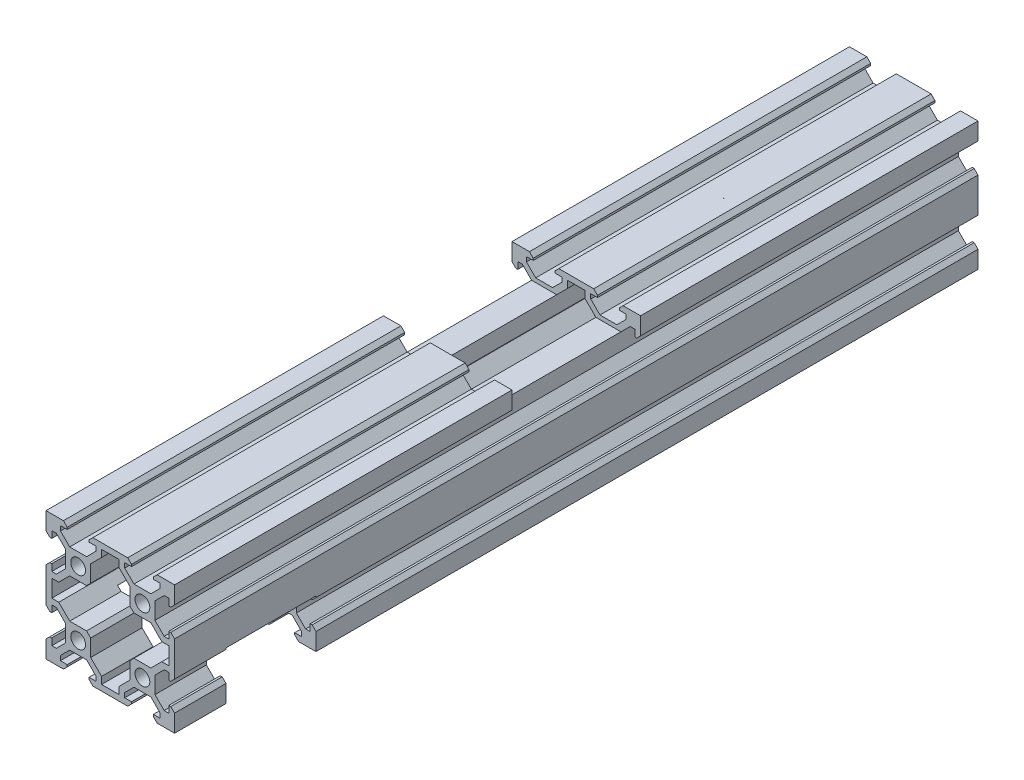
from build123d import *

# Parameters (mm, degrees)
SKETCH1_W           = 40
SKETCH1_H           = 40
BOSS_EXTRUDE1_DEPTH = 250
SKETCH2_R           = 2.3
CUT_EXTRUDE1_DEPTH  = 250
CUT_EXTRUDE2_DEPTH  = 250
SKETCH4_W           = 40
SKETCH4_H           = 7.372792206
CUT_EXTRUDE3_DEPTH  = 41
SKETCH5_W           = 28
SKETCH5_H           = 15
CABLE_GAP_DEPTH     = 40


with BuildPart() as part:
    # Sketch1 → Boss-Extrude1 (new body)
    with BuildSketch(Plane.XY):
        with Locations((20, 20)):
            Rectangle(SKETCH1_W, SKETCH1_H)
    extrude(amount=-BOSS_EXTRUDE1_DEPTH)

    # Sketch2 → Cut-Extrude1 (cut)
    with BuildSketch(Plane.XY):
        with Locations((10, 30)):
            Circle(SKETCH2_R)
        with Locations((30, 30)):
            Circle(SKETCH2_R)
        with Locations((30, 10)):
            Circle(SKETCH2_R)
        with Locations((10, 10)):
            Circle(SKETCH2_R)
        Polygon((6.605, 38.815), (6.605, 38.2), (4.5, 38.2), (4.5, 36.772792206), (7.372792206, 33.9), (12.627207794, 33.9), (15.5, 36.772792206), (15.5, 38.2), (13.395, 38.2), (13.395, 38.815), (14.58, 40), (5.42, 40), align=None)
        Polygon((26.605, 38.815), (25.42, 40), (34.58, 40), (33.395, 38.815), (33.395, 38.2), (35.5, 38.2), (35.5, 36.772792206), (32.627207794, 33.9), (27.372792206, 33.9), (24.5, 36.772792206), (24.5, 38.2), (26.605, 38.2), align=None)
        Polygon((26.605, 1.8), (26.605, 1.185), (25.42, 0), (34.58, 0), (33.395, 1.185), (33.395, 1.8), (35.5, 1.8), (35.5, 3.227207794), (32.627207794, 6.1), (27.372792206, 6.1), (24.5, 3.227207794), (24.5, 1.8), align=None)
        Polygon((13.395, 1.185), (14.58, 0), (5.42, 0), (6.605, 1.185), (6.605, 1.8), (4.5, 1.8), (4.5, 3.227207794), (7.372792206, 6.1), (12.627207794, 6.1), (15.5, 3.227207794), (15.5, 1.8), (13.395, 1.8), align=None)
        Polygon((1.8, 13.395), (1.185, 13.395), (0, 14.58), (0, 5.42), (1.185, 6.605), (1.8, 6.605), (1.8, 4.5), (3.227207794, 4.5), (6.1, 7.372792206), (6.1, 12.627207794), (3.227207794, 15.5), (1.8, 15.5), align=None)
        Polygon((1.185, 26.605), (0, 25.42), (0, 34.58), (1.185, 33.395), (1.8, 33.395), (1.8, 35.5), (3.227207794, 35.5), (6.1, 32.627207794), (6.1, 27.372792206), (3.227207794, 24.5), (1.8, 24.5), (1.8, 26.605), align=None)
        Polygon((38.2, 15.5), (38.2, 13.395), (38.815, 13.395), (40, 14.58), (40, 5.42), (38.815, 6.605), (38.2, 6.605), (38.2, 4.5), (36.772792206, 4.5), (33.9, 7.372792206), (33.9, 12.627207794), (36.772792206, 15.5), align=None)
        Polygon((38.2, 26.605), (38.815, 26.605), (40, 25.42), (40, 34.58), (38.815, 33.395), (38.2, 33.395), (38.2, 35.5), (36.772792206, 35.5), (33.9, 32.627207794), (33.9, 27.372792206), (36.772792206, 24.5), (38.2, 24.5), align=None)
    extrude(amount=-CUT_EXTRUDE1_DEPTH, mode=Mode.SUBTRACT)

    # Sketch3 → Cut-Extrude2 (cut)
    with BuildSketch(Plane.XY):
        Polygon((17.3, 38.2), (22.7, 38.2), (22.7, 36.027207794), (26.1, 32.627207794), (26.1, 27.372792206), (27.372792206, 26.1), (32.627207794, 26.1), (36.027207794, 22.7), (38.2, 22.7), (38.2, 17.3), (36.027207794, 17.3), (32.627207794, 13.9), (27.372792206, 13.9), (26.1, 12.627207794), (26.1, 7.372792206), (22.7, 3.972792206), (22.7, 1.8), (17.3, 1.8), (17.3, 3.972792206), (13.9, 7.372792206), (13.9, 12.627207794), (12.627207794, 13.9), (7.372792206, 13.9), (3.972792206, 17.3), (1.8, 17.3), (1.8, 22.7), (3.972792206, 22.7), (7.372792206, 26.1), (12.627207794, 26.1), (13.9, 27.372792206), (13.9, 32.627207794), (17.3, 36.027207794), align=None)
    extrude(amount=-CUT_EXTRUDE2_DEPTH, mode=Mode.SUBTRACT)

    # Sketch4 → Cut-Extrude3 (cut, through all)
    with BuildSketch(Plane(origin=(40, 0, 0), x_dir=(0, 0, -1), z_dir=(1, 0, 0))):
        with Locations((125, 36.313603897)):
            Rectangle(SKETCH4_W, SKETCH4_H)
    extrude(amount=-CUT_EXTRUDE3_DEPTH, mode=Mode.SUBTRACT)

    # Sketch5 → cable gap (cut)
    with BuildSketch(Plane.ZY):
        with Locations((-30, 7.5)):
            Rectangle(SKETCH5_W, SKETCH5_H)
    extrude(amount=-CABLE_GAP_DEPTH, mode=Mode.SUBTRACT)


solid = part.part
